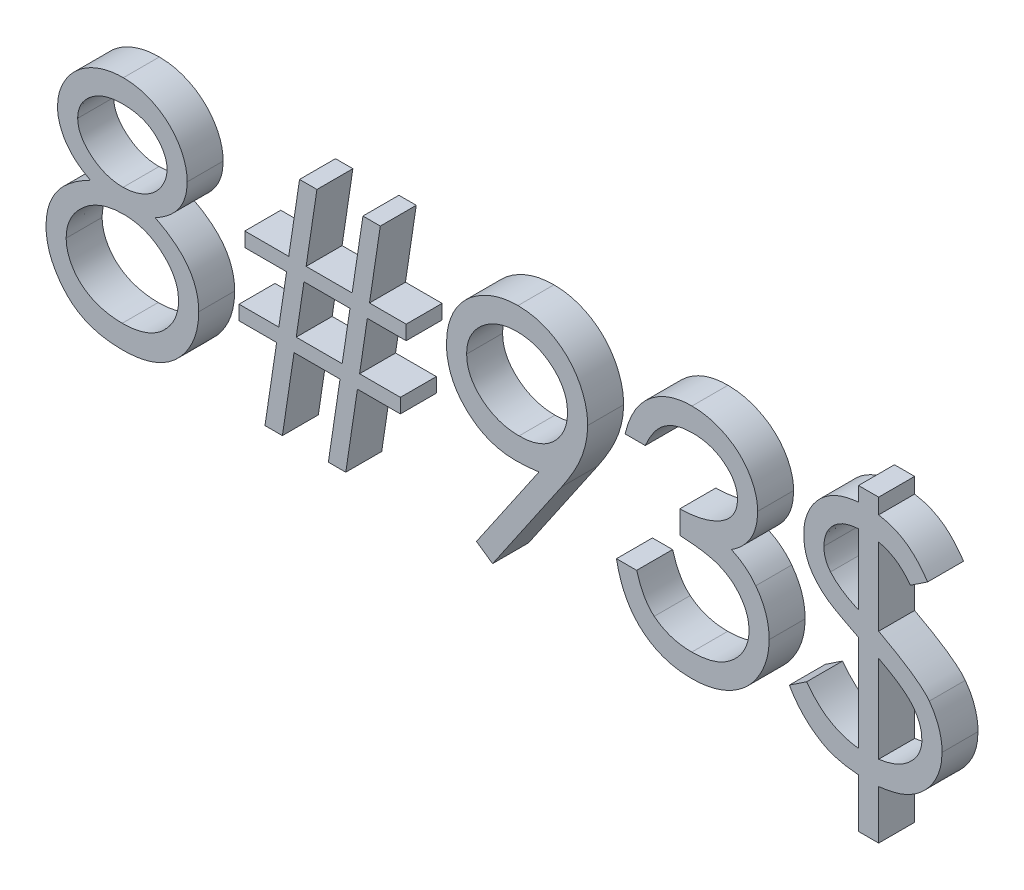
from build123d import *

# Parameters (mm, degrees)
BOSS_EXTRUDE1_DEPTH   = 2.54
BOSS_EXTRUDE1_2_DEPTH = 2.54
BOSS_EXTRUDE1_3_DEPTH = 2.54
BOSS_EXTRUDE1_4_DEPTH = 2.54
BOSS_EXTRUDE1_5_DEPTH = 2.54


with BuildPart() as part:
    # Sketch1 → Boss-Extrude1 (new body)
    with BuildSketch(Plane.XY):
        with BuildLine():
            add(Edge.make_bspline(
                [(-27.231349159, 8.84382512), (-27.101407534, 8.77607082), (-26.84797797, 8.643927307), (-26.48703849, 8.431153195), (-26.157178663, 8.206903105), (-25.849246472, 7.981769028), (-25.568651988, 7.747129038), (-25.318532687, 7.502050079), (-25.092710268, 7.252649542), (-24.895738783, 6.994704195), (-24.722488845, 6.728899323), (-24.572755232, 6.454537263), (-24.444770062, 6.172219285), (-24.343338161, 5.878863663), (-24.259782178, 5.578779619), (-24.202289255, 5.268092344), (-24.171369663, 4.948849084), (-24.165523974, 4.733092858), (-24.162564103, 4.623848157)],
                knots=[0, 0, 0, 0, 1.272397273, 2.481599622, 3.635517121, 4.734568067, 5.792894095, 6.808321871, 7.773003508, 8.711915296, 9.623354172, 10.525449501, 11.423591555, 12.311487226, 13.218079475, 14.126165749, 15.051214107, 16, 16, 16, 16], degree=3))
            add(Edge.make_bspline(
                [(-24.162564103, 4.623848157), (-24.166063046, 4.47100487), (-24.172988767, 4.168470655), (-24.233313695, 3.721947221), (-24.323633276, 3.288279496), (-24.455529635, 2.867562555), (-24.626586801, 2.462117897), (-24.837392449, 2.071598461), (-25.076021844, 1.689603737), (-25.267665929, 1.454565737), (-25.36463742, 1.335637019)],
                knots=[0, 0, 0, 0, 1.025265484, 2.029385089, 3.018602448, 3.995076438, 4.983346944, 5.966715145, 6.97116228, 8, 8, 8, 8], degree=3))
            add(Edge.make_bspline(
                [(-25.36463742, 1.335637019), (-25.490895714, 1.196872401), (-25.741852094, 0.921057916), (-26.171760372, 0.562959599), (-26.643573917, 0.262017705), (-27.155467069, 0.01676304), (-27.706071493, -0.174126391), (-28.295269871, -0.311297812), (-28.92421085, -0.389867402), (-29.356489237, -0.401224783), (-29.578254207, -0.407051282)],
                knots=[0, 0, 0, 0, 0.954267603, 1.896743057, 2.838368354, 3.796610408, 4.779680527, 5.799409237, 6.871065594, 8, 8, 8, 8], degree=3))
            add(Edge.make_bspline(
                [(-29.578254207, -0.407051282), (-29.791493505, -0.401823971), (-30.20643552, -0.391652156), (-30.810401608, -0.322734555), (-31.373388389, -0.20195816), (-31.898669317, -0.036655825), (-32.383077676, 0.178383425), (-32.82523317, 0.446028708), (-33.231515116, 0.755507035), (-33.589593764, 1.115706604), (-33.90749492, 1.50150481), (-34.186750018, 1.89952104), (-34.418861017, 2.309791626), (-34.615380342, 2.726199077), (-34.765821016, 3.154579848), (-34.870016399, 3.592729907), (-34.936189359, 4.039883948), (-34.944993792, 4.341652518), (-34.949423077, 4.493464543)],
                knots=[0, 0, 0, 0, 1.256902934, 2.445805442, 3.576955095, 4.645999104, 5.686449165, 6.692658513, 7.68621702, 8.689161843, 9.678783111, 10.630372946, 11.551080876, 12.453998257, 13.34127905, 14.221779781, 15.105423033, 16, 16, 16, 16], degree=3))
            add(Edge.make_bspline(
                [(-34.949423077, 4.493464543), (-34.946801974, 4.604858021), (-34.941621749, 4.825010852), (-34.905767615, 5.150263876), (-34.848125666, 5.466839202), (-34.769841701, 5.775906147), (-34.663746688, 6.075214633), (-34.535648442, 6.366182853), (-34.386278514, 6.649139301), (-34.21355323, 6.925631369), (-34.012611907, 7.191784871), (-33.785083924, 7.452116704), (-33.526421805, 7.702587315), (-33.239503138, 7.946256885), (-32.927606834, 8.18744791), (-32.582631607, 8.413125679), (-32.213722606, 8.639267162), (-31.951533802, 8.774469209), (-31.817036258, 8.84382512)],
                knots=[0, 0, 0, 0, 0.941657376, 1.861047343, 2.762797495, 3.66048619, 4.553285746, 5.444104102, 6.34607688, 7.256116206, 8.197091036, 9.162375105, 10.176350973, 11.237807142, 12.343728897, 13.50695164, 14.721116704, 16, 16, 16, 16], degree=3))
            add(Edge.make_bspline(
                [(-31.817036258, 8.84382512), (-32.001147136, 8.944222106), (-32.357637328, 9.138618773), (-32.829666579, 9.495791786), (-33.235116907, 9.882632946), (-33.562843662, 10.307310944), (-33.820799839, 10.756559267), (-33.997777081, 11.227567126), (-34.117503991, 11.711600926), (-34.1293641, 12.042282604), (-34.135320513, 12.208358373)],
                knots=[0, 0, 0, 0, 1.166880483, 2.259407225, 3.286803203, 4.280235371, 5.237608625, 6.161067461, 7.076446754, 8, 8, 8, 8], degree=3))
            add(Edge.make_bspline(
                [(-34.135320513, 12.208358373), (-34.127902696, 12.377529442), (-34.112991592, 12.717592792), (-33.992417245, 13.22380628), (-33.7959298, 13.7209957), (-33.528680992, 14.206751254), (-33.195817548, 14.664632585), (-32.796463572, 15.075300449), (-32.340155761, 15.435034673), (-31.829171865, 15.737005171), (-31.279278938, 15.982766766), (-30.699089762, 16.152304612), (-30.098713168, 16.263139856), (-29.690055655, 16.275688611), (-29.482851562, 16.282051282)],
                knots=[0, 0, 0, 0, 0.888701115, 1.786444228, 2.72001202, 3.692817113, 4.693886446, 5.687152267, 6.695133018, 7.739871481, 8.800368666, 9.853104506, 10.91144658, 12, 12, 12, 12], degree=3))
            add(Edge.make_bspline(
                [(-29.482851562, 16.282051282), (-29.280994973, 16.275491083), (-28.882956775, 16.262555118), (-28.297874, 16.154664635), (-27.73805402, 15.974462885), (-27.205427364, 15.730000479), (-26.709529251, 15.428888283), (-26.271368777, 15.06421289), (-25.884324566, 14.655356571), (-25.56417392, 14.197614084), (-25.300363672, 13.713725063), (-25.116663156, 13.2074372), (-24.998952417, 12.689689683), (-24.984105372, 12.339360166), (-24.976666667, 12.163837139)],
                knots=[0, 0, 0, 0, 1.072916533, 2.115669174, 3.151510826, 4.193348718, 5.225979165, 6.227137561, 7.216255879, 8.211077061, 9.189680878, 10.138522389, 11.067357538, 12, 12, 12, 12], degree=3))
            add(Edge.make_bspline(
                [(-24.976666667, 12.163837139), (-24.983173424, 11.991585843), (-24.995952325, 11.653294086), (-25.103448479, 11.160141654), (-25.284483866, 10.698305977), (-25.53165382, 10.262546516), (-25.853805138, 9.860766151), (-26.246637606, 9.487855734), (-26.70701931, 9.140751906), (-27.052916902, 8.944870897), (-27.231349159, 8.84382512)],
                knots=[0, 0, 0, 0, 0.975232327, 1.915300861, 2.843280834, 3.77672583, 4.742871857, 5.749627742, 6.839139064, 8, 8, 8, 8], degree=3))
        make_face()
        with BuildLine():
            add(Edge.make_bspline(
                [(-29.562353766, 14.653846154), (-29.673709207, 14.650891406), (-29.89156914, 14.645110626), (-30.211013469, 14.614908951), (-30.514780993, 14.556156861), (-30.806045517, 14.47796699), (-31.080813701, 14.37233933), (-31.342817216, 14.248083395), (-31.58759697, 14.097016598), (-31.81810788, 13.927556879), (-32.025620322, 13.741171198), (-32.209790967, 13.546980402), (-32.362772056, 13.341170588), (-32.492679945, 13.128861242), (-32.586938971, 12.903751128), (-32.657534207, 12.672741864), (-32.705256232, 12.432914229), (-32.708832144, 12.269009342), (-32.710641026, 12.186097756)],
                knots=[0, 0, 0, 0, 1.203892937, 2.355340988, 3.463153438, 4.544400666, 5.610487187, 6.640501085, 7.674077295, 8.714426146, 9.728707835, 10.68524104, 11.601827946, 12.495867327, 13.368432065, 14.231010473, 15.105153427, 16, 16, 16, 16], degree=3))
            add(Edge.make_bspline(
                [(-32.710641026, 12.186097756), (-32.707523326, 12.103182588), (-32.701362303, 11.939330304), (-32.653714044, 11.697368698), (-32.582699024, 11.459599131), (-32.470890666, 11.231675356), (-32.336786113, 11.005690834), (-32.171271203, 10.787293533), (-31.974017398, 10.575723395), (-31.751642937, 10.372779929), (-31.509383462, 10.182739111), (-31.252734409, 10.017760752), (-30.984916848, 9.879720322), (-30.708682462, 9.764833379), (-30.421215933, 9.675525449), (-30.124278714, 9.61216766), (-29.8178209, 9.572788603), (-29.610173266, 9.568084971), (-29.505112179, 9.565705128)],
                knots=[0, 0, 0, 0, 0.873023192, 1.725219244, 2.590779336, 3.480155217, 4.391973325, 5.357036234, 6.360879153, 7.436073238, 8.526419356, 9.601555421, 10.645666583, 11.697338044, 12.750135903, 13.812665442, 14.89329948, 16, 16, 16, 16], degree=3))
            add(Edge.make_bspline(
                [(-29.505112179, 9.565705128), (-29.370174209, 9.569664204), (-29.101631041, 9.577543253), (-28.70575693, 9.650800362), (-28.320844221, 9.766034346), (-27.951007048, 9.923695622), (-27.605818393, 10.121579129), (-27.298115227, 10.358493175), (-27.030522177, 10.62896733), (-26.805820124, 10.928790907), (-26.631604034, 11.247885611), (-26.495977978, 11.568108367), (-26.416778894, 11.892875629), (-26.406448501, 12.110440072), (-26.401346154, 12.217898638)],
                knots=[0, 0, 0, 0, 1.076279235, 2.141928126, 3.20205304, 4.278698113, 5.344010996, 6.36967002, 7.368914609, 8.37248503, 9.349703398, 10.264243087, 11.142681841, 12, 12, 12, 12], degree=3))
            add(Edge.make_bspline(
                [(-26.401346154, 12.217898638), (-26.403758689, 12.293318658), (-26.408547226, 12.443016587), (-26.448008194, 12.664079887), (-26.513212866, 12.88011407), (-26.601491836, 13.092903798), (-26.717650548, 13.299463547), (-26.855373827, 13.50304041), (-27.022671387, 13.699054767), (-27.210433781, 13.892074577), (-27.423364742, 14.070709256), (-27.661053915, 14.227802406), (-27.922282712, 14.361208451), (-28.207057306, 14.469561018), (-28.514328926, 14.550942389), (-28.842682321, 14.611885824), (-29.194855348, 14.646235294), (-29.437197433, 14.651254177), (-29.562353766, 14.653846154)],
                knots=[0, 0, 0, 0, 0.814439003, 1.616544685, 2.417341072, 3.248991801, 4.09997495, 4.973547432, 5.9003056, 6.880240646, 7.880314356, 8.896779544, 9.951930927, 11.043077905, 12.18215768, 13.381699519, 14.647792085, 16, 16, 16, 16], degree=3))
        make_face(mode=Mode.SUBTRACT)
        with BuildLine():
            add(Edge.make_bspline(
                [(-29.47013121, 7.9375), (-29.61130888, 7.934988841), (-29.888265021, 7.93006256), (-30.294016088, 7.87522804), (-30.683421517, 7.798894721), (-31.055168372, 7.683094132), (-31.409099668, 7.532524337), (-31.747131407, 7.351392674), (-32.066677602, 7.137282271), (-32.363325682, 6.892913336), (-32.634213641, 6.629572242), (-32.871877358, 6.350797557), (-33.073705398, 6.061770355), (-33.236234786, 5.758819886), (-33.369637999, 5.44836108), (-33.457240228, 5.122662344), (-33.513400134, 4.787985081), (-33.520941356, 4.560473206), (-33.52474359, 4.445763221)],
                knots=[0, 0, 0, 0, 1.140299081, 2.23698856, 3.303958914, 4.344563908, 5.37730929, 6.408454204, 7.439741482, 8.480804886, 9.510774543, 10.48932336, 11.43758569, 12.353841022, 13.263987381, 14.161954604, 15.073269652, 16, 16, 16, 16], degree=3))
            add(Edge.make_bspline(
                [(-33.52474359, 4.445763221), (-33.518560237, 4.303201611), (-33.506292611, 4.020362708), (-33.408971428, 3.602337349), (-33.252781677, 3.197656136), (-33.034953019, 2.809616922), (-32.765225101, 2.446986083), (-32.433544336, 2.130897708), (-32.060523393, 1.850039573), (-31.633540984, 1.622888582), (-31.167140441, 1.441483346), (-30.661445814, 1.316497373), (-30.123714575, 1.233759368), (-29.752422853, 1.225421903), (-29.562353766, 1.221153846)],
                knots=[0, 0, 0, 0, 0.898778495, 1.783155532, 2.693654817, 3.627872908, 4.583023416, 5.533784346, 6.509005473, 7.520592997, 8.575161974, 9.658835044, 10.801527049, 12, 12, 12, 12], degree=3))
            add(Edge.make_bspline(
                [(-29.562353766, 1.221153846), (-29.413807454, 1.224005941), (-29.124391604, 1.229562738), (-28.702180336, 1.278613287), (-28.303742562, 1.356399085), (-27.92985094, 1.469535882), (-27.576319953, 1.607648275), (-27.249143668, 1.785321645), (-26.939905349, 1.987398253), (-26.663843078, 2.227147749), (-26.412413881, 2.4833226), (-26.193187876, 2.754513153), (-26.002880412, 3.033349056), (-25.853515005, 3.326131612), (-25.73410664, 3.627243689), (-25.648274803, 3.939461901), (-25.595314826, 4.26374385), (-25.589958621, 4.48372178), (-25.58724359, 4.595227364)],
                knots=[0, 0, 0, 0, 1.224942928, 2.386581632, 3.501229538, 4.569074225, 5.605009692, 6.626002462, 7.634866581, 8.645888296, 9.63523824, 10.59253846, 11.518950513, 12.414518923, 13.29783783, 14.186679152, 15.080837789, 16, 16, 16, 16], degree=3))
            add(Edge.make_bspline(
                [(-25.58724359, 4.595227364), (-25.59135226, 4.703528159), (-25.59945384, 4.917078408), (-25.650873833, 5.233519439), (-25.741206561, 5.539239347), (-25.865155825, 5.837916159), (-26.030169478, 6.123498114), (-26.224501566, 6.403425034), (-26.458971319, 6.669927479), (-26.723914166, 6.925075451), (-27.012653023, 7.161003971), (-27.319571859, 7.369712317), (-27.642308169, 7.545480844), (-27.980179018, 7.688430663), (-28.332434183, 7.800859543), (-28.698814571, 7.87939995), (-29.079749142, 7.928837434), (-29.338533735, 7.934579856), (-29.47013121, 7.9375)],
                knots=[0, 0, 0, 0, 0.917430815, 1.809013306, 2.70690318, 3.612392954, 4.541220862, 5.495268465, 6.494511384, 7.542276156, 8.608045339, 9.649016899, 10.681629292, 11.715607085, 12.752076957, 13.808767841, 14.885711793, 16, 16, 16, 16], degree=3))
        make_face(mode=Mode.SUBTRACT)
    extrude(amount=BOSS_EXTRUDE1_DEPTH)


with BuildPart() as body_2:
    # Sketch1 → Boss-Extrude1 2 (new body)
    with BuildSketch(Plane.XY):
        Polygon((-9.915769231, 6.512820513), (-9.915769231, 5.495192308), (-12.949573317, 5.495192308), (-13.773216146, 0), (-15.003910256, 0), (-14.180267428, 5.495192308), (-17.42713742, 5.495192308), (-18.250780248, 0), (-19.481474359, 0), (-18.65783153, 5.495192308), (-21.313205128, 5.495192308), (-21.313205128, 6.512820513), (-18.5051873, 6.512820513), (-17.955032051, 10.176282051), (-20.906153846, 10.176282051), (-20.906153846, 11.193910256), (-17.802387821, 11.193910256), (-17.039166667, 16.282051282), (-15.811652644, 16.282051282), (-16.574873798, 11.193910256), (-13.324823718, 11.193910256), (-12.561602564, 16.282051282), (-11.334088542, 16.282051282), (-12.097309696, 11.193910256), (-9.508717949, 11.193910256), (-9.508717949, 10.176282051), (-12.249953926, 10.176282051), (-12.796929087, 6.512820513), align=None)
        Polygon((-13.477467949, 10.176282051), (-16.727518029, 10.176282051), (-17.274493189, 6.512820513), (-14.027623197, 6.512820513), align=None, mode=Mode.SUBTRACT)
    extrude(amount=BOSS_EXTRUDE1_2_DEPTH)


with BuildPart() as body_3:
    # Sketch1 → Boss-Extrude1 3 (new body)
    with BuildSketch(Plane.XY):
        with BuildLine():
            Line((-3.402948718, -0.407051282), (-4.541420272, 0.384790665))
            Line((-4.541420272, 0.384790665), (-0.127457933, 6.837189503))
            add(Edge.make_bspline(
                [(-0.127457933, 6.837189503), (-0.409083769, 6.802749537), (-0.963620743, 6.734935325), (-1.522135456, 6.722477284), (-1.797004207, 6.716346154)],
                knots=[0, 0, 0, 0, 1.015715272, 2, 2, 2, 2], degree=3))
            add(Edge.make_bspline(
                [(-1.797004207, 6.716346154), (-1.963655638, 6.720614608), (-2.290777824, 6.72899321), (-2.771707105, 6.795404269), (-3.233830898, 6.897685205), (-3.675924048, 7.050306344), (-4.09964823, 7.239981792), (-4.50407843, 7.47519039), (-4.888670219, 7.751897498), (-5.249293115, 8.068639996), (-5.577278502, 8.416429734), (-5.869484174, 8.784528543), (-6.112331451, 9.17721241), (-6.314064534, 9.586470905), (-6.467056235, 10.018186318), (-6.578464887, 10.467446097), (-6.647055566, 10.937398902), (-6.655215749, 11.257280745), (-6.659358974, 11.419696514)],
                knots=[0, 0, 0, 0, 1.060718605, 2.082097864, 3.085795603, 4.069760067, 5.054557537, 6.03741023, 7.043284206, 8.066802108, 9.088538119, 10.083643548, 11.053783639, 12.022749082, 12.983451788, 13.964007469, 14.966251758, 16, 16, 16, 16], degree=3))
            add(Edge.make_bspline(
                [(-6.659358974, 11.419696514), (-6.651492074, 11.641804332), (-6.636050944, 12.077756922), (-6.511779098, 12.714724374), (-6.307398273, 13.317006197), (-6.022426707, 13.883018862), (-5.663494221, 14.404620286), (-5.23210883, 14.874559335), (-4.73089442, 15.286152065), (-4.171268833, 15.639956273), (-3.566417632, 15.924504296), (-2.932920504, 16.134232552), (-2.27563146, 16.257598302), (-1.830370956, 16.273862743), (-1.606198918, 16.282051282)],
                knots=[0, 0, 0, 0, 1.022988612, 2.007919123, 2.978103895, 3.94594894, 4.918897164, 5.887013414, 6.875921846, 7.89917871, 8.930658928, 9.948724884, 10.967259574, 12, 12, 12, 12], degree=3))
            add(Edge.make_bspline(
                [(-1.606198918, 16.282051282), (-1.386269301, 16.273750185), (-0.951709106, 16.257348001), (-0.312676827, 16.137224284), (0.299377072, 15.934765089), (0.88105969, 15.654981532), (1.419627738, 15.304275987), (1.903932311, 14.886380111), (2.322921363, 14.401033613), (2.67590825, 13.859975104), (2.959254505, 13.278646297), (3.163689502, 12.671840648), (3.289535794, 12.043922162), (3.305394134, 11.618497226), (3.313397436, 11.403796074)],
                knots=[0, 0, 0, 0, 1.026385292, 2.028040595, 3.023318987, 4.028184125, 5.03290303, 6.015178782, 7.004435299, 8.016004309, 9.023023918, 10.015172535, 10.998308025, 12, 12, 12, 12], degree=3))
            add(Edge.make_bspline(
                [(3.313397436, 11.403796074), (3.30805251, 11.237136844), (3.297211664, 10.899110285), (3.221300557, 10.385529801), (3.092394717, 9.86187601), (2.946110226, 9.418638772), (2.804903608, 9.052568304), (2.672002047, 8.763409352), (2.524536208, 8.459057193), (2.352547521, 8.142703196), (2.16766139, 7.810314555), (1.958749671, 7.465225095), (1.73057797, 7.106971733), (1.568064599, 6.865458155), (1.484846755, 6.741786859)],
                knots=[0, 0, 0, 0, 1.179839688, 2.393009684, 3.667231171, 4.993948276, 5.694988576, 6.444077775, 7.246288328, 8.089075292, 8.993003841, 9.939041771, 10.944649915, 12, 12, 12, 12], degree=3))
            Line((1.484846755, 6.741786859), (-3.402948718, -0.407051282))
        make_face()
        with BuildLine():
            add(Edge.make_bspline(
                [(-1.533056891, 8.344551282), (-1.406809756, 8.348000166), (-1.161049502, 8.354713969), (-0.801016753, 8.395577316), (-0.461181973, 8.468030753), (-0.140637378, 8.571988019), (0.16383107, 8.697430767), (0.447387273, 8.857142275), (0.710268543, 9.047717727), (0.954235212, 9.261848869), (1.170879068, 9.49974973), (1.3638421, 9.748747321), (1.527856102, 10.009934659), (1.657410966, 10.28658267), (1.763930291, 10.571957152), (1.83749056, 10.870653691), (1.878240928, 11.18111608), (1.885187715, 11.392020707), (1.888717949, 11.499198718)],
                knots=[0, 0, 0, 0, 1.163407946, 2.26475976, 3.333800367, 4.359385343, 5.366239384, 6.363380779, 7.350133999, 8.353570782, 9.349036268, 10.310270964, 11.253520213, 12.184142, 13.120487599, 14.056272588, 15.012232024, 16, 16, 16, 16], degree=3))
            add(Edge.make_bspline(
                [(1.888717949, 11.499198718), (1.885680521, 11.606421485), (1.879694896, 11.8177171), (1.83167393, 12.128639135), (1.747195239, 12.426604996), (1.633845541, 12.713245946), (1.484528748, 12.986206919), (1.305352223, 13.248914909), (1.09248004, 13.499704202), (0.847539829, 13.732676557), (0.583404535, 13.947433099), (0.301915838, 14.136962801), (0.005393897, 14.295808942), (-0.304352253, 14.426886412), (-0.627967979, 14.529174823), (-0.965261782, 14.602732156), (-1.317938086, 14.643425471), (-1.55733892, 14.65032835), (-1.679340946, 14.653846154)],
                knots=[0, 0, 0, 0, 0.972161553, 1.915763587, 2.844109794, 3.775983486, 4.705125789, 5.659731448, 6.655561913, 7.682237399, 8.721216875, 9.739758359, 10.754845918, 11.767244016, 12.7857855, 13.828538656, 14.893392813, 16, 16, 16, 16], degree=3))
            add(Edge.make_bspline(
                [(-1.679340946, 14.653846154), (-1.800281927, 14.650322667), (-2.037567136, 14.643409616), (-2.387108145, 14.602809507), (-2.722121299, 14.528680132), (-3.044799363, 14.426933792), (-3.354536309, 14.295799164), (-3.651044264, 14.136954478), (-3.932598805, 13.947476727), (-4.19648086, 13.732507581), (-4.441853578, 13.500788614), (-4.651065798, 13.247816276), (-4.83065238, 12.986343576), (-4.979764, 12.713209628), (-5.093168275, 12.426614689), (-5.177632354, 12.128636509), (-5.225657246, 11.817717784), (-5.231642332, 11.606421716), (-5.234679487, 11.499198718)],
                knots=[0, 0, 0, 0, 1.099389452, 2.15699305, 3.192601482, 4.213358962, 5.227959689, 6.245255729, 7.266013209, 8.307253147, 9.336162325, 10.327954924, 11.284637477, 12.215801273, 13.149702402, 14.080068371, 15.025723358, 16, 16, 16, 16], degree=3))
            add(Edge.make_bspline(
                [(-5.234679487, 11.499198718), (-5.231931179, 11.391937245), (-5.226511014, 11.180397989), (-5.174224253, 10.86958185), (-5.086783484, 10.57163897), (-4.969674105, 10.283672335), (-4.815452607, 10.008482121), (-4.626205154, 9.747373015), (-4.40438357, 9.49738508), (-4.152953108, 9.262402369), (-3.877779664, 9.046719287), (-3.583880137, 8.85834934), (-3.276314091, 8.699270753), (-2.953998837, 8.571629476), (-2.619322995, 8.469069431), (-2.269278649, 8.395710851), (-1.905023429, 8.355105926), (-1.658235297, 8.348103251), (-1.533056891, 8.344551282)],
                knots=[0, 0, 0, 0, 0.952633368, 1.87876736, 2.791047057, 3.707742249, 4.635551637, 5.587206343, 6.568248508, 7.601284464, 8.641511608, 9.671105535, 10.699146789, 11.713763218, 12.747829548, 13.806491675, 14.887386225, 16, 16, 16, 16], degree=3))
        make_face(mode=Mode.SUBTRACT)
    extrude(amount=BOSS_EXTRUDE1_3_DEPTH)


with BuildPart() as body_4:
    # Sketch1 → Boss-Extrude1 4 (new body)
    with BuildSketch(Plane.XY):
        with BuildLine():
            Line((7.383910256, 12.211538462), (5.959230769, 12.211538462))
            add(Edge.make_bspline(
                [(5.959230769, 12.211538462), (5.99782766, 12.371342942), (6.073281424, 12.683747632), (6.230659704, 13.13009485), (6.402106325, 13.552476537), (6.607978335, 13.942983728), (6.832535899, 14.309464466), (7.089813958, 14.643606566), (7.367942699, 14.953908231), (7.675577291, 15.22928613), (7.998196577, 15.478649401), (8.34034646, 15.691261269), (8.695143156, 15.874160105), (9.065044866, 16.024837585), (9.451152859, 16.13834621), (9.849976508, 16.220700293), (10.262560955, 16.274181418), (10.542630384, 16.279400951), (10.684841747, 16.282051282)],
                knots=[0, 0, 0, 0, 1.162005537, 2.271625781, 3.343758855, 4.383309926, 5.390229558, 6.379919256, 7.361854164, 8.333198761, 9.295911338, 10.242430842, 11.177959212, 12.116337295, 13.062827104, 14.020064771, 14.994644689, 16, 16, 16, 16], degree=3))
            add(Edge.make_bspline(
                [(10.684841747, 16.282051282), (10.892045613, 16.275795488), (11.301933627, 16.263420356), (11.904108875, 16.150415591), (12.484801948, 15.971594455), (13.03765675, 15.724517192), (13.551183212, 15.419774736), (14.008093774, 15.057077537), (14.402195233, 14.643423562), (14.732823303, 14.186529431), (14.991699192, 13.698234799), (15.182590957, 13.195676944), (15.298803582, 12.680048002), (15.313864679, 12.331898914), (15.321410256, 12.157476963)],
                knots=[0, 0, 0, 0, 1.083050992, 2.142477498, 3.193116406, 4.255571735, 5.30263384, 6.308962982, 7.297363603, 8.282367274, 9.249857812, 10.179914175, 11.08814088, 12, 12, 12, 12], degree=3))
            add(Edge.make_bspline(
                [(15.321410256, 12.157476963), (15.31613254, 11.989624716), (15.305804868, 11.661163915), (15.218112703, 11.18164141), (15.070537511, 10.72969558), (14.866113945, 10.303423881), (14.601493342, 9.905529072), (14.280942181, 9.535115924), (13.902197965, 9.190541528), (13.615182782, 8.993149633), (13.46741887, 8.891526442)],
                knots=[0, 0, 0, 0, 1.024540389, 2.004866551, 2.965041327, 3.920577974, 4.882998113, 5.874504559, 6.905732034, 8, 8, 8, 8], degree=3))
            add(Edge.make_bspline(
                [(13.46741887, 8.891526442), (13.636291471, 8.809982593), (13.970876937, 8.648420642), (14.42694541, 8.331574885), (14.840955773, 7.965740738), (15.071840499, 7.680250848), (15.187846554, 7.536808894)],
                knots=[0, 0, 0, 0, 1.015518401, 2.012035669, 3.001164323, 4, 4, 4, 4], degree=3))
            add(Edge.make_bspline(
                [(15.187846554, 7.536808894), (15.264234072, 7.432225521), (15.415758207, 7.224771399), (15.602790807, 6.891231182), (15.772467861, 6.55399407), (15.904684927, 6.20402105), (16.007073538, 5.845368452), (16.080261969, 5.477420441), (16.125728608, 5.099876554), (16.132239862, 4.844459233), (16.135512821, 4.716070713)],
                knots=[0, 0, 0, 0, 1.025084078, 2.033381695, 3.024893161, 4.013698104, 4.991890475, 5.976764909, 6.982997093, 8, 8, 8, 8], degree=3))
            add(Edge.make_bspline(
                [(16.135512821, 4.716070713), (16.12737342, 4.493776621), (16.111132923, 4.050234555), (15.965971586, 3.394938496), (15.740940101, 2.754379968), (15.42136757, 2.14171909), (15.031897084, 1.568493791), (14.568540649, 1.05561196), (14.036563011, 0.614746862), (13.443265961, 0.24640047), (12.800477557, -0.048048677), (12.112973979, -0.252416364), (11.390661234, -0.385521434), (10.895328134, -0.399794732), (10.643500601, -0.407051282)],
                knots=[0, 0, 0, 0, 0.955779014, 1.907060117, 2.875433937, 3.871313158, 4.872415639, 5.851225146, 6.836215519, 7.83643374, 8.849228613, 9.86973379, 10.916971861, 12, 12, 12, 12], degree=3))
            add(Edge.make_bspline(
                [(10.643500601, -0.407051282), (10.473777346, -0.403113315), (10.139818577, -0.395364708), (9.648856995, -0.34239391), (9.180219287, -0.245647101), (8.733271825, -0.115457108), (8.307617553, 0.049605436), (7.904555362, 0.255158102), (7.521605487, 0.496963844), (7.162381673, 0.777876903), (6.826926741, 1.092117265), (6.524155456, 1.445263489), (6.249019967, 1.830787428), (6.008887284, 2.253167004), (5.792819678, 2.706943707), (5.615106053, 3.197927967), (5.458689367, 3.721730496), (5.385966154, 4.086754532), (5.348653846, 4.274038462)],
                knots=[0, 0, 0, 0, 1.048658725, 2.063410685, 3.046034179, 4.001477787, 4.936774919, 5.862367409, 6.792675028, 7.730719943, 8.675894397, 9.627829632, 10.600096036, 11.597688215, 12.626045268, 13.701542398, 14.82072376, 16, 16, 16, 16], degree=3))
            Line((5.348653846, 4.274038462), (6.773333333, 4.274038462))
            add(Edge.make_bspline(
                [(6.773333333, 4.274038462), (6.810450405, 4.151805437), (6.882646334, 3.914051587), (7.005538329, 3.571875915), (7.145547991, 3.258194745), (7.295746168, 2.970707013), (7.453491262, 2.706581474), (7.629998244, 2.472802282), (7.81219401, 2.259101186), (7.949532505, 2.13870241), (8.016747796, 2.079777644)],
                knots=[0, 0, 0, 0, 1.198163088, 2.33053128, 3.407730985, 4.417276592, 5.372219308, 6.28897303, 7.162600585, 8, 8, 8, 8], degree=3))
            add(Edge.make_bspline(
                [(8.016747796, 2.079777644), (8.105632269, 2.011250558), (8.283126847, 1.874407914), (8.572361323, 1.699775528), (8.876548485, 1.548459448), (9.202279329, 1.432872686), (9.542524895, 1.335002581), (9.90278473, 1.270955941), (10.279880465, 1.227013164), (10.537362821, 1.223135439), (10.668941306, 1.221153846)],
                knots=[0, 0, 0, 0, 0.946170439, 1.889420265, 2.845303464, 3.807233317, 4.801018734, 5.828864929, 6.890507805, 8, 8, 8, 8], degree=3))
            add(Edge.make_bspline(
                [(10.668941306, 1.221153846), (10.817501836, 1.223947416), (11.107999127, 1.229410002), (11.531883668, 1.279646244), (11.935142448, 1.35280919), (12.313298218, 1.465807362), (12.671304448, 1.60542051), (13.004142645, 1.780718635), (13.316182126, 1.986389336), (13.603426215, 2.220156235), (13.861714767, 2.476068016), (14.089133274, 2.743734445), (14.28246656, 3.022026958), (14.438420646, 3.312485578), (14.561567785, 3.613907509), (14.645402302, 3.927138628), (14.703693103, 4.249615514), (14.708440237, 4.468821908), (14.710833333, 4.579326923)],
                knots=[0, 0, 0, 0, 1.217147791, 2.380027433, 3.494444702, 4.572153297, 5.609568379, 6.639424714, 7.649109417, 8.668170816, 9.669597737, 10.625200337, 11.543417969, 12.441394052, 13.322311151, 14.205496177, 15.095365482, 16, 16, 16, 16], degree=3))
            add(Edge.make_bspline(
                [(14.710833333, 4.579326923), (14.703892323, 4.727242639), (14.690044839, 5.022338062), (14.584323783, 5.456485631), (14.410429649, 5.87478468), (14.166986472, 6.270098442), (13.870642274, 6.636474853), (13.524272875, 6.963370505), (13.125001983, 7.233109847), (12.757519005, 7.419476253), (12.432012759, 7.546644415), (12.153450123, 7.631348718), (11.841589815, 7.703074942), (11.500203161, 7.769805602), (11.126717858, 7.82659886), (10.721540514, 7.873959953), (10.284589024, 7.911856032), (9.98209695, 7.928779214), (9.826217949, 7.9375)],
                knots=[0, 0, 0, 0, 1.07054697, 2.135767047, 3.216561865, 4.33974944, 5.486079747, 6.621378074, 7.775625952, 8.963672916, 9.598146892, 10.304877434, 11.070270905, 11.915000392, 12.823868403, 13.805723172, 14.86925407, 16, 16, 16, 16], degree=3))
            Line((9.826217949, 7.9375), (9.826217949, 9.565705128))
            add(Edge.make_bspline(
                [(9.826217949, 9.565705128), (10.022619665, 9.569037988), (10.407322379, 9.575566241), (10.969271547, 9.654524003), (11.506632642, 9.763746852), (12.007496793, 9.931047545), (12.4640106, 10.125358892), (12.860067367, 10.35147427), (13.190118356, 10.60281974), (13.452559645, 10.88327479), (13.649995789, 11.184060898), (13.794353048, 11.49755431), (13.879625957, 11.826502729), (13.891009089, 12.050996401), (13.896730769, 12.163837139)],
                knots=[0, 0, 0, 0, 1.321986639, 2.589447074, 3.816329219, 5.01088745, 6.139805852, 7.153945165, 8.075214402, 8.924034688, 9.728124013, 10.488707548, 11.240355623, 12, 12, 12, 12], degree=3))
            add(Edge.make_bspline(
                [(13.896730769, 12.163837139), (13.89485112, 12.246739769), (13.891111646, 12.411670619), (13.843952564, 12.652630752), (13.773086378, 12.886224328), (13.675660463, 13.111457968), (13.545257776, 13.326769567), (13.389202052, 13.533994782), (13.203382454, 13.731950494), (12.990451319, 13.916464801), (12.761797775, 14.092310983), (12.511200581, 14.241597837), (12.24621565, 14.369255797), (11.966549608, 14.474527467), (11.671294881, 14.55371781), (11.361838709, 14.610576805), (11.037591002, 14.646126168), (10.81637636, 14.65124434), (10.703922276, 14.653846154)],
                knots=[0, 0, 0, 0, 0.884392785, 1.759457502, 2.611959086, 3.489218968, 4.37281399, 5.2945488, 6.255912374, 7.266815255, 8.301784654, 9.332968512, 10.37626691, 11.440494194, 12.520033166, 13.637162961, 14.798855837, 16, 16, 16, 16], degree=3))
            add(Edge.make_bspline(
                [(10.703922276, 14.653846154), (10.523166496, 14.647535333), (10.170108417, 14.635208833), (9.661133615, 14.527245165), (9.187970922, 14.354987429), (8.826299113, 14.149369805), (8.55922458, 13.946394623), (8.36837561, 13.769128085), (8.180957581, 13.572129206), (8.009300404, 13.343264433), (7.835700581, 13.09803292), (7.677655606, 12.823968364), (7.524077716, 12.528219862), (7.43153758, 12.319143234), (7.383910256, 12.211538462)],
                knots=[0, 0, 0, 0, 1.472543308, 2.876219568, 4.221790263, 5.565193594, 6.249813518, 6.953379497, 7.687249741, 8.463570142, 9.283606569, 10.136032583, 11.040678096, 12, 12, 12, 12], degree=3))
        make_face()
    extrude(amount=BOSS_EXTRUDE1_4_DEPTH)


with BuildPart() as body_5:
    # Sketch1 → Boss-Extrude1 5 (new body)
    with BuildSketch(Plane.XY):
        with BuildLine():
            Line((22.444807692, 17.299679487), (23.869487179, 17.299679487))
            Line((23.869487179, 17.299679487), (23.869487179, 16.215269431))
            add(Edge.make_bspline(
                [(23.869487179, 16.215269431), (24.051683872, 16.179877973), (24.405786976, 16.111093928), (24.910292542, 15.946353663), (25.373703726, 15.736942934), (25.802255752, 15.476670467), (26.206731437, 15.1620762), (26.593619296, 14.783037576), (26.975730656, 14.341285383), (27.208267281, 14.011544543), (27.329423077, 13.83974359)],
                knots=[0, 0, 0, 0, 1.027584432, 1.997131963, 2.932839691, 3.839392674, 4.768682057, 5.765560961, 6.83581677, 8, 8, 8, 8], degree=3))
            Line((27.329423077, 13.83974359), (26.108269231, 13.025641026))
            add(Edge.make_bspline(
                [(26.108269231, 13.025641026), (26.033583974, 13.12552966), (25.886538867, 13.322196788), (25.641240088, 13.590240934), (25.378950513, 13.824393033), (25.107964663, 14.035922785), (24.818305962, 14.208973612), (24.516017729, 14.353636803), (24.200364737, 14.470808801), (23.980420752, 14.520606563), (23.869487179, 14.545723157)],
                knots=[0, 0, 0, 0, 1.078886086, 2.1241799, 3.137384888, 4.118952335, 5.09432795, 6.050315663, 7.016633946, 8, 8, 8, 8], degree=3))
            Line((23.869487179, 14.545723157), (23.869487179, 9.095052083))
            add(Edge.make_bspline(
                [(23.869487179, 9.095052083), (24.098111938, 8.972318984), (24.535966926, 8.737264391), (25.152001019, 8.380133331), (25.70380765, 8.045719891), (26.184444521, 7.723841094), (26.59953283, 7.422967826), (26.946874591, 7.141112724), (27.230481544, 6.879237383), (27.378903081, 6.69571257), (27.447086338, 6.611403245)],
                knots=[0, 0, 0, 0, 1.421563521, 2.722533998, 3.90086193, 4.955909988, 5.891017391, 6.708270612, 7.406593414, 8, 8, 8, 8], degree=3))
            add(Edge.make_bspline(
                [(27.447086338, 6.611403245), (27.518375912, 6.509471436), (27.659384036, 6.307854112), (27.845737955, 5.992758326), (27.99766381, 5.665661791), (28.125644386, 5.332422114), (28.224873858, 4.990946397), (28.293650548, 4.641837611), (28.341683678, 4.284912208), (28.345250616, 4.043113707), (28.347051282, 3.921048678)],
                knots=[0, 0, 0, 0, 1.034043855, 2.045300251, 3.038849623, 4.029149086, 5.010980087, 5.991029359, 6.985828872, 8, 8, 8, 8], degree=3))
            add(Edge.make_bspline(
                [(28.347051282, 3.921048678), (28.339220717, 3.721147929), (28.323737116, 3.325878444), (28.196519889, 2.746941485), (27.981532963, 2.19751322), (27.694643577, 1.676312113), (27.329852482, 1.202128763), (26.91075736, 0.77234767), (26.426795639, 0.404289337), (26.069613373, 0.2076449), (25.888843149, 0.108122997)],
                knots=[0, 0, 0, 0, 1.003148038, 1.983553384, 2.959265273, 3.957656479, 4.960564385, 5.95430431, 6.964671814, 8, 8, 8, 8], degree=3))
            add(Edge.make_bspline(
                [(25.888843149, 0.108122997), (25.756374953, 0.050021935), (25.473854722, -0.073892528), (24.998360782, -0.206975098), (24.458235655, -0.326153728), (24.072464129, -0.379161038), (23.869487179, -0.407051282)],
                knots=[0, 0, 0, 0, 0.828774769, 1.767561174, 2.825383437, 4, 4, 4, 4], degree=3))
            Line((23.869487179, -0.407051282), (23.869487179, -3.866987179))
            Line((23.869487179, -3.866987179), (22.444807692, -3.866987179))
            Line((22.444807692, -3.866987179), (22.444807692, -0.407051282))
            add(Edge.make_bspline(
                [(22.444807692, -0.407051282), (22.236734315, -0.387428684), (21.841243744, -0.350131492), (21.281540056, -0.256092011), (20.78814671, -0.129780839), (20.347846805, 0.024435465), (19.946716033, 0.222261293), (19.561182672, 0.460108413), (19.17796164, 0.738012471), (18.803536469, 1.056625103), (18.444967767, 1.409685467), (18.118523544, 1.797214647), (17.815840862, 2.205508556), (17.645508979, 2.498885332), (17.560192308, 2.645833333)],
                knots=[0, 0, 0, 0, 1.246369877, 2.369008186, 3.381156714, 4.281134999, 5.14644078, 6.043237309, 6.980405317, 7.967295389, 8.973263283, 9.97797855, 10.987199957, 12, 12, 12, 12], degree=3))
            Line((17.560192308, 2.645833333), (18.781346154, 3.459935897))
            add(Edge.make_bspline(
                [(18.781346154, 3.459935897), (18.903493546, 3.299524064), (19.142472297, 2.985681754), (19.543549866, 2.565759632), (19.962377816, 2.193462388), (20.415656184, 1.891106438), (20.884384472, 1.629157192), (21.384573977, 1.438532242), (21.905271267, 1.294277242), (22.26380675, 1.245684912), (22.444807692, 1.221153846)],
                knots=[0, 0, 0, 0, 1.091287229, 2.135080052, 3.140258803, 4.119656891, 5.080569621, 6.042305372, 7.011688971, 8, 8, 8, 8], degree=3))
            Line((22.444807692, 1.221153846), (22.444807692, 8.007461939))
            add(Edge.make_bspline(
                [(22.444807692, 8.007461939), (22.312022824, 8.074766591), (22.05954099, 8.20274203), (21.703561285, 8.393699763), (21.380926066, 8.55776231), (21.103120121, 8.71804348), (20.855631704, 8.848197901), (20.651273003, 8.969313704), (20.48315516, 9.071250064), (20.386048408, 9.136107892), (20.342769431, 9.165014022)],
                knots=[0, 0, 0, 0, 1.488100894, 2.829527543, 4.03819425, 5.105512503, 6.034940557, 6.832790355, 7.479792712, 8, 8, 8, 8], degree=3))
            add(Edge.make_bspline(
                [(20.342769431, 9.165014022), (20.200590322, 9.272521063), (19.924966171, 9.480930985), (19.559716516, 9.830206877), (19.252057138, 10.196101883), (19.001370491, 10.582846091), (18.813184216, 10.996132929), (18.673903734, 11.435445209), (18.594963261, 11.907668805), (18.583635176, 12.232453118), (18.577820513, 12.399163662)],
                knots=[0, 0, 0, 0, 1.111925663, 2.155545704, 3.146753046, 4.090165088, 5.022748513, 5.972842731, 6.959467941, 8, 8, 8, 8], degree=3))
            add(Edge.make_bspline(
                [(18.577820513, 12.399163662), (18.58299764, 12.561755504), (18.593262746, 12.884139462), (18.685369206, 13.358033308), (18.83604044, 13.812817496), (19.043608025, 14.246499697), (19.302965975, 14.650646499), (19.606908636, 15.019382991), (19.953451034, 15.347142525), (20.346349198, 15.632743844), (20.788778759, 15.878013165), (21.290319679, 16.06682698), (21.847262952, 16.20811446), (22.240518321, 16.256773665), (22.444807692, 16.282051282)],
                knots=[0, 0, 0, 0, 0.966390721, 1.916140824, 2.859274721, 3.809715285, 4.768215958, 5.70875375, 6.645436948, 7.597632791, 8.591005287, 9.644890604, 10.776561346, 12, 12, 12, 12], degree=3))
            Line((22.444807692, 16.282051282), (22.444807692, 17.299679487))
        make_face()
        with BuildLine():
            add(Edge.make_bspline(
                [(22.444807692, 14.653846154), (22.311971719, 14.640392306), (22.058279809, 14.614697969), (21.699361753, 14.539391737), (21.381157076, 14.431191891), (21.101319202, 14.293711684), (20.856089647, 14.129139625), (20.639505907, 13.939294641), (20.4519839, 13.720958204), (20.288959968, 13.481085158), (20.163419833, 13.219895703), (20.06775475, 12.94530012), (20.014340014, 12.655640494), (20.006469386, 12.457666523), (20.0025, 12.357822516)],
                knots=[0, 0, 0, 0, 1.288684447, 2.461146705, 3.5326112, 4.525981788, 5.462845056, 6.376666015, 7.298193862, 8.235057129, 9.168951999, 10.088260048, 11.035854185, 12, 12, 12, 12], degree=3))
            add(Edge.make_bspline(
                [(20.0025, 12.357822516), (20.007220389, 12.231035217), (20.016392162, 11.984686004), (20.110420645, 11.632147935), (20.255418126, 11.306474429), (20.398201088, 11.119400788), (20.469972957, 11.025365585)],
                knots=[0, 0, 0, 0, 1.053300573, 2.046575394, 3.018083574, 4, 4, 4, 4], degree=3))
            add(Edge.make_bspline(
                [(20.469972957, 11.025365585), (20.585233032, 10.900738619), (20.828588563, 10.63760621), (21.288165564, 10.30041367), (21.827609648, 9.968373873), (22.231539068, 9.781850113), (22.444807692, 9.683368389)],
                knots=[0, 0, 0, 0, 0.84476628, 1.783605858, 2.829777417, 4, 4, 4, 4], degree=3))
            Line((22.444807692, 9.683368389), (22.444807692, 14.653846154))
        make_face(mode=Mode.SUBTRACT)
        with BuildLine():
            add(Edge.make_bspline(
                [(23.869487179, 1.26567508), (23.983187266, 1.282120639), (24.205595876, 1.314289779), (24.527575488, 1.388088103), (24.831513682, 1.480507383), (25.118823711, 1.591646864), (25.388278234, 1.722404134), (25.64286511, 1.86757923), (25.874107588, 2.038742092), (26.090517043, 2.220906741), (26.28286228, 2.418835661), (26.456402163, 2.620433032), (26.599844058, 2.832432705), (26.718861859, 3.04791016), (26.808288331, 3.271682731), (26.876070805, 3.499029361), (26.915026337, 3.734207946), (26.919911002, 3.892291085), (26.922371795, 3.971930088)],
                knots=[0, 0, 0, 0, 1.238409242, 2.422450928, 3.55782164, 4.661624594, 5.740343964, 6.785286318, 7.81644612, 8.83805853, 9.832253583, 10.789421395, 11.702507017, 12.587396983, 13.438570116, 14.295861374, 15.141490349, 16, 16, 16, 16], degree=3))
            add(Edge.make_bspline(
                [(26.922371795, 3.971930088), (26.914011614, 4.127403955), (26.897392255, 4.436473353), (26.775414479, 4.889913334), (26.569539184, 5.321188872), (26.335837549, 5.663434284), (26.102991033, 5.929434005), (25.889292363, 6.134532638), (25.641230479, 6.344403291), (25.354594088, 6.554864939), (25.035369266, 6.773061763), (24.678743797, 6.990703658), (24.287592016, 7.213787369), (24.012027382, 7.357518675), (23.869487179, 7.431865986)],
                knots=[0, 0, 0, 0, 1.147666952, 2.281468529, 3.44082769, 4.663498593, 5.329350128, 6.049176811, 6.849192394, 7.727696536, 8.67454676, 9.704539109, 10.81263624, 12, 12, 12, 12], degree=3))
            Line((23.869487179, 7.431865986), (23.869487179, 1.26567508))
        make_face(mode=Mode.SUBTRACT)
    extrude(amount=BOSS_EXTRUDE1_5_DEPTH)


solid = Compound([part.part, body_2.part, body_3.part, body_4.part, body_5.part])
